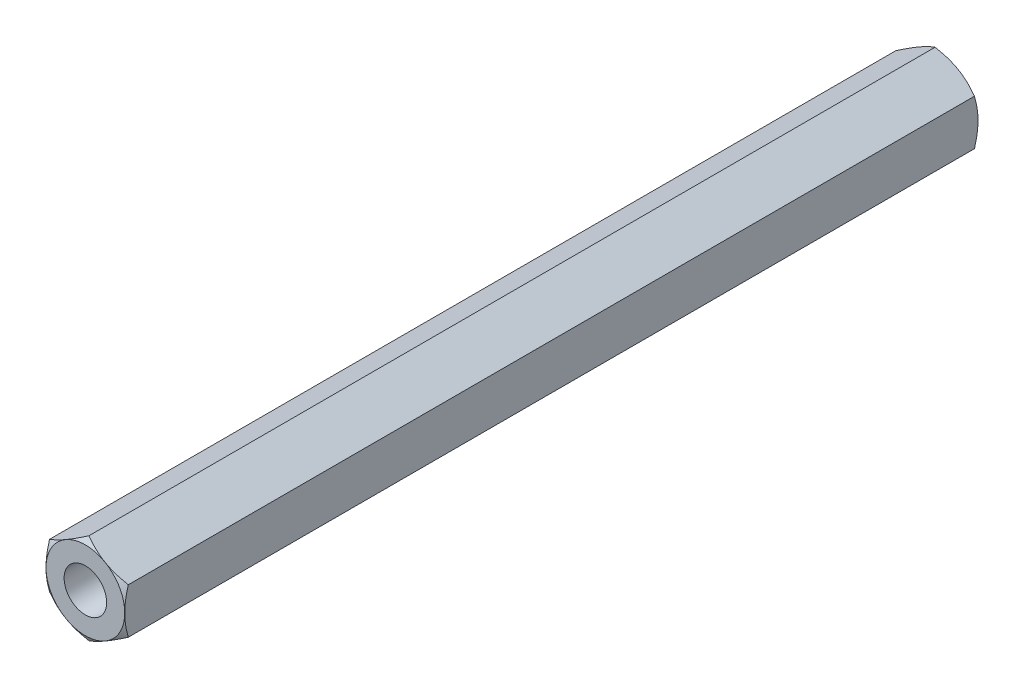
from build123d import *

# Parameters (mm, degrees)
SKETCH_1_R          = 1.621125
EXTRUDE_700_DEPTH   = 65
SKETCH_2_OUTSIDE_W  = 249.76
SKETCH_2_OUTSIDE_H  = 250.688
SKETCH_2_OUTSIDE_R  = 3
CUT_EXTRUDE_1_DEPTH = 66
CUT_EXTRUDE_1_TAPER = 60
SKETCH_3_OUTSIDE_W  = 249.76
SKETCH_3_OUTSIDE_H  = 250.688
SKETCH_3_OUTSIDE_R  = 3
CUT_EXTRUDE_2_DEPTH = 66
CUT_EXTRUDE_2_TAPER = 60


with BuildPart() as part:
    # 草图1 → Extrude 700 (new body)
    with BuildSketch(Plane.XY):
        Polygon((0, 3.464101615), (-3, 1.732050808), (-3, -1.732050808), (0, -3.464101615), (3, -1.732050808), (3, 1.732050808), align=None)
        Circle(SKETCH_1_R, mode=Mode.SUBTRACT)
    extrude(amount=EXTRUDE_700_DEPTH)

    # 草图2 outside → 切除-拉伸1 (cut, through all)
    with BuildSketch(Plane(origin=(0, 0, 0), x_dir=(-1, 0, 0), z_dir=(0, 0, -1))):
        Rectangle(SKETCH_2_OUTSIDE_W, SKETCH_2_OUTSIDE_H)
        Circle(SKETCH_2_OUTSIDE_R, mode=Mode.SUBTRACT)
    extrude(amount=-CUT_EXTRUDE_1_DEPTH, taper=CUT_EXTRUDE_1_TAPER, mode=Mode.SUBTRACT)

    # 草图3 outside → 切除-拉伸2 (cut, through all)
    with BuildSketch(Plane.XY.offset(65)):
        Rectangle(SKETCH_3_OUTSIDE_W, SKETCH_3_OUTSIDE_H)
        Circle(SKETCH_3_OUTSIDE_R, mode=Mode.SUBTRACT)
    extrude(amount=-CUT_EXTRUDE_2_DEPTH, taper=CUT_EXTRUDE_2_TAPER, mode=Mode.SUBTRACT)


solid = part.part
